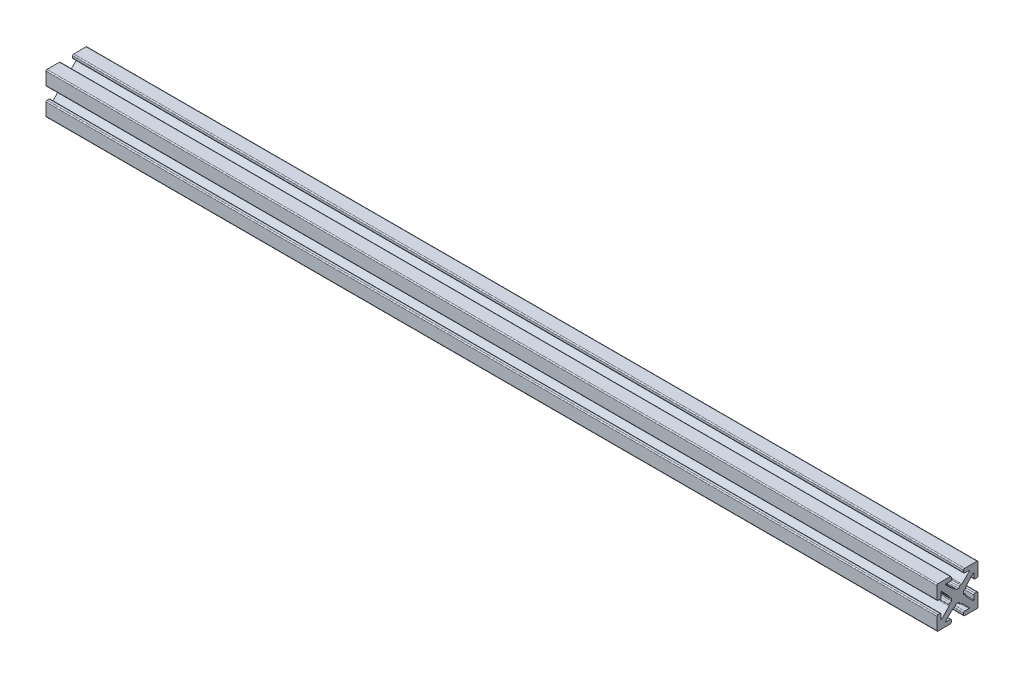
from build123d import *

# Parameters (mm, degrees)
BOSS_EXTRU_1_DEPTH = 217


with BuildPart() as part:
    # Sketch1 → Boss.-Extru.1 (new body)
    with BuildSketch(Plane(origin=(0, 0, 0), x_dir=(0, 0, -1), z_dir=(1, 0, 0))):
        with BuildLine():
            Line((-0.2413, 1.4986), (0.2413, 1.4986))
            ThreePointArc((0.2413, 1.4986), (0.420905122, 1.572994878), (0.4953, 1.7526))
            ThreePointArc((0.4953, 1.7526), (0.569694878, 1.932205122), (0.7493, 2.0066))
            Line((0.7493, 2.0066), (0.889923986, 2.0066))
            ThreePointArc((0.889923986, 2.0066), (0.983516259, 2.024471886), (1.063937899, 2.075572548))
            Line((1.063937899, 2.075572548), (2.890793, 3.793686274))
            ThreePointArc((2.890793, 3.793686274), (2.921850101, 3.932996137), (2.803786044, 4.0132))
            Line((2.803786044, 4.0132), (1.7526, 4.0132))
            ThreePointArc((1.7526, 4.0132), (1.572994878, 4.087594878), (1.4986, 4.2672))
            Line((1.4986, 4.2672), (1.4986, 4.7498))
            ThreePointArc((1.4986, 4.7498), (1.572994878, 4.929405122), (1.7526, 5.0038))
            Line((1.7526, 5.0038), (4.7498, 5.0038))
            ThreePointArc((4.7498, 5.0038), (4.929405122, 4.929405122), (5.0038, 4.7498))
            Line((5.0038, 4.7498), (5.0038, 1.7526))
            ThreePointArc((5.0038, 1.7526), (4.929405122, 1.572994878), (4.7498, 1.4986))
            Line((4.7498, 1.4986), (4.2672, 1.4986))
            ThreePointArc((4.2672, 1.4986), (4.087594878, 1.572994878), (4.0132, 1.7526))
            Line((4.0132, 1.7526), (4.0132, 2.803786044))
            ThreePointArc((4.0132, 2.803786044), (3.932996137, 2.921850101), (3.793686274, 2.890793))
            Line((3.793686274, 2.890793), (2.075572548, 1.063937899))
            ThreePointArc((2.075572548, 1.063937899), (2.024471886, 0.983516259), (2.0066, 0.889923986))
            Line((2.0066, 0.889923986), (2.0066, 0.7493))
            ThreePointArc((2.0066, 0.7493), (1.932205122, 0.569694878), (1.7526, 0.4953))
            ThreePointArc((1.7526, 0.4953), (1.572994878, 0.420905122), (1.4986, 0.2413))
            Line((1.4986, 0.2413), (1.4986, -0.2413))
            ThreePointArc((1.4986, -0.2413), (1.572994878, -0.420905122), (1.7526, -0.4953))
            ThreePointArc((1.7526, -0.4953), (1.932205122, -0.569694878), (2.0066, -0.7493))
            Line((2.0066, -0.7493), (2.0066, -0.889923986))
            ThreePointArc((2.0066, -0.889923986), (2.024471886, -0.983516259), (2.075572548, -1.063937899))
            Line((2.075572548, -1.063937899), (3.793686274, -2.890793))
            ThreePointArc((3.793686274, -2.890793), (3.932996137, -2.921850101), (4.0132, -2.803786044))
            Line((4.0132, -2.803786044), (4.0132, -1.7526))
            ThreePointArc((4.0132, -1.7526), (4.087594878, -1.572994878), (4.2672, -1.4986))
            Line((4.2672, -1.4986), (4.7498, -1.4986))
            ThreePointArc((4.7498, -1.4986), (4.929405122, -1.572994878), (5.0038, -1.7526))
            Line((5.0038, -1.7526), (5.0038, -4.7498))
            ThreePointArc((5.0038, -4.7498), (4.929405122, -4.929405122), (4.7498, -5.0038))
            Line((4.7498, -5.0038), (1.7526, -5.0038))
            ThreePointArc((1.7526, -5.0038), (1.572994878, -4.929405122), (1.4986, -4.7498))
            Line((1.4986, -4.7498), (1.4986, -4.2672))
            ThreePointArc((1.4986, -4.2672), (1.572994878, -4.087594878), (1.7526, -4.0132))
            Line((1.7526, -4.0132), (2.803786044, -4.0132))
            ThreePointArc((2.803786044, -4.0132), (2.921850101, -3.932996137), (2.890793, -3.793686274))
            Line((2.890793, -3.793686274), (1.063937899, -2.075572548))
            ThreePointArc((1.063937899, -2.075572548), (0.983516259, -2.024471886), (0.889923986, -2.0066))
            Line((0.889923986, -2.0066), (0.7493, -2.0066))
            ThreePointArc((0.7493, -2.0066), (0.569694878, -1.932205122), (0.4953, -1.7526))
            ThreePointArc((0.4953, -1.7526), (0.420905122, -1.572994878), (0.2413, -1.4986))
            Line((0.2413, -1.4986), (-0.2413, -1.4986))
            ThreePointArc((-0.2413, -1.4986), (-0.420905122, -1.572994878), (-0.4953, -1.7526))
            ThreePointArc((-0.4953, -1.7526), (-0.569694878, -1.932205122), (-0.7493, -2.0066))
            Line((-0.7493, -2.0066), (-0.889923986, -2.0066))
            ThreePointArc((-0.889923986, -2.0066), (-0.983516259, -2.024471886), (-1.063937899, -2.075572548))
            Line((-1.063937899, -2.075572548), (-2.890793, -3.793686274))
            ThreePointArc((-2.890793, -3.793686274), (-2.921850101, -3.932996137), (-2.803786044, -4.0132))
            Line((-2.803786044, -4.0132), (-1.7526, -4.0132))
            ThreePointArc((-1.7526, -4.0132), (-1.572994878, -4.087594878), (-1.4986, -4.2672))
            Line((-1.4986, -4.2672), (-1.4986, -4.7498))
            ThreePointArc((-1.4986, -4.7498), (-1.572994878, -4.929405122), (-1.7526, -5.0038))
            Line((-1.7526, -5.0038), (-4.7498, -5.0038))
            ThreePointArc((-4.7498, -5.0038), (-4.929405122, -4.929405122), (-5.0038, -4.7498))
            Line((-5.0038, -4.7498), (-5.0038, -1.7526))
            ThreePointArc((-5.0038, -1.7526), (-4.929405122, -1.572994878), (-4.7498, -1.4986))
            Line((-4.7498, -1.4986), (-4.2672, -1.4986))
            ThreePointArc((-4.2672, -1.4986), (-4.087594878, -1.572994878), (-4.0132, -1.7526))
            Line((-4.0132, -1.7526), (-4.0132, -2.803786044))
            ThreePointArc((-4.0132, -2.803786044), (-3.932996137, -2.921850101), (-3.793686274, -2.890793))
            Line((-3.793686274, -2.890793), (-2.075572548, -1.063937899))
            ThreePointArc((-2.075572548, -1.063937899), (-2.024471886, -0.983516259), (-2.0066, -0.889923986))
            Line((-2.0066, -0.889923986), (-2.0066, -0.7493))
            ThreePointArc((-2.0066, -0.7493), (-1.932205122, -0.569694878), (-1.7526, -0.4953))
            ThreePointArc((-1.7526, -0.4953), (-1.572994878, -0.420905122), (-1.4986, -0.2413))
            Line((-1.4986, -0.2413), (-1.4986, 0.2413))
            ThreePointArc((-1.4986, 0.2413), (-1.572994878, 0.420905122), (-1.7526, 0.4953))
            ThreePointArc((-1.7526, 0.4953), (-1.932205122, 0.569694878), (-2.0066, 0.7493))
            Line((-2.0066, 0.7493), (-2.0066, 0.889923986))
            ThreePointArc((-2.0066, 0.889923986), (-2.024471886, 0.983516259), (-2.075572548, 1.063937899))
            Line((-2.075572548, 1.063937899), (-3.793686274, 2.890793))
            ThreePointArc((-3.793686274, 2.890793), (-3.932996137, 2.921850101), (-4.0132, 2.803786044))
            Line((-4.0132, 2.803786044), (-4.0132, 1.7526))
            ThreePointArc((-4.0132, 1.7526), (-4.087594878, 1.572994878), (-4.2672, 1.4986))
            Line((-4.2672, 1.4986), (-4.7498, 1.4986))
            ThreePointArc((-4.7498, 1.4986), (-4.929405122, 1.572994878), (-5.0038, 1.7526))
            Line((-5.0038, 1.7526), (-5.0038, 4.7498))
            ThreePointArc((-5.0038, 4.7498), (-4.929405122, 4.929405122), (-4.7498, 5.0038))
            Line((-4.7498, 5.0038), (-1.7526, 5.0038))
            ThreePointArc((-1.7526, 5.0038), (-1.572994878, 4.929405122), (-1.4986, 4.7498))
            Line((-1.4986, 4.7498), (-1.4986, 4.2672))
            ThreePointArc((-1.4986, 4.2672), (-1.572994878, 4.087594878), (-1.7526, 4.0132))
            Line((-1.7526, 4.0132), (-2.803786044, 4.0132))
            ThreePointArc((-2.803786044, 4.0132), (-2.921850101, 3.932996137), (-2.890793, 3.793686274))
            Line((-2.890793, 3.793686274), (-1.063937899, 2.075572548))
            ThreePointArc((-1.063937899, 2.075572548), (-0.983516259, 2.024471886), (-0.889923986, 2.0066))
            Line((-0.889923986, 2.0066), (-0.7493, 2.0066))
            ThreePointArc((-0.7493, 2.0066), (-0.569694878, 1.932205122), (-0.4953, 1.7526))
            ThreePointArc((-0.4953, 1.7526), (-0.420905122, 1.572994878), (-0.2413, 1.4986))
        make_face()
    extrude(amount=BOSS_EXTRU_1_DEPTH)


solid = part.part
